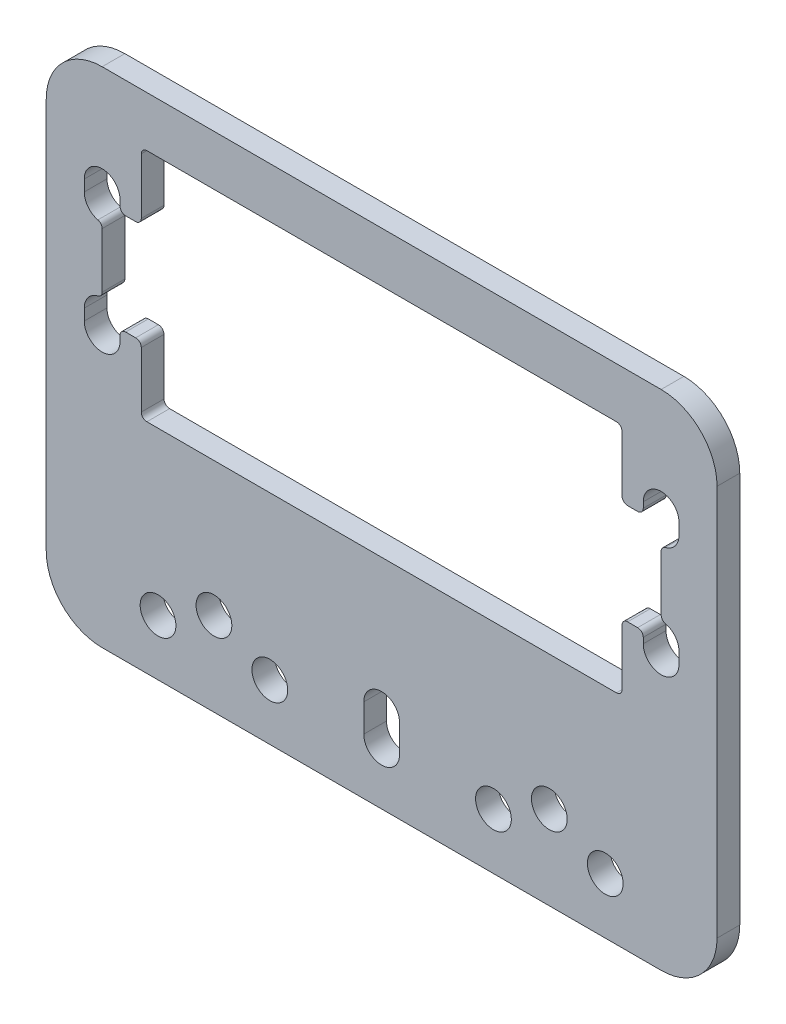
from build123d import *

# Parameters (mm, degrees)
SKETCH1_W           = 60
SKETCH1_H           = 45
BOSS_EXTRUDE1_DEPTH = 2.032
FILLET1_R           = 5
SKETCH2_W           = 41
SKETCH2_H           = 21
CUT_EXTRUDE1_DEPTH  = 3.032
FILLET2_R           = 0.5
CUT_EXTRUDE2_DEPTH  = 3.032
SKETCH4_R           = 1.6
CUT_EXTRUDE3_DEPTH  = 3.032
CUT_EXTRUDE4_DEPTH  = 3.032
FILLET3_R           = 0.5


with BuildPart() as part:
    # Sketch1 → Boss-Extrude1 (new body)
    with BuildSketch(Plane.XY):
        Rectangle(SKETCH1_W, SKETCH1_H)
    extrude(amount=BOSS_EXTRUDE1_DEPTH)

    # Fillet1
    fillet1_edges = [part.edges().sort_by_distance(p)[0] for p in [
        (30, -22.5, 1.016),
        (-30, -22.5, 1.016),
        (-30, 22.5, 1.016),
        (30, 22.5, 1.016),
    ]]
    fillet(fillet1_edges, radius=FILLET1_R)

    # Sketch2 → Cut-Extrude1 (cut, through all)
    with BuildSketch(Plane.XY.offset(2.032)):
        with Locations((0, 7.5)):
            Rectangle(SKETCH2_W, SKETCH2_H)
    extrude(amount=-CUT_EXTRUDE1_DEPTH, mode=Mode.SUBTRACT)

    # Fillet2
    fillet2_edges = [part.edges().sort_by_distance(p)[0] for p in [
        (20.5, 18, 1.016),
        (20.5, -3, 1.016),
        (-20.5, -3, 1.016),
        (-20.5, 18, 1.016),
    ]]
    fillet(fillet2_edges, radius=FILLET2_R)

    # Sketch3 → Cut-Extrude2 (cut, through all)
    with BuildSketch(Plane.XY.offset(2.032)):
        with BuildLine():
            Line((-23.4, 3), (-23.4, 2))
            ThreePointArc((-23.4, 2), (-25, 0.4), (-26.6, 2))
            Line((-26.6, 2), (-26.6, 3))
            ThreePointArc((-26.6, 3), (-25, 4.6), (-23.4, 3))
        make_face()
        with BuildLine():
            Line((-23.4, 12), (-23.4, 13))
            ThreePointArc((-23.4, 13), (-25, 14.6), (-26.6, 13))
            Line((-26.6, 13), (-26.6, 12))
            ThreePointArc((-26.6, 12), (-25, 10.4), (-23.4, 12))
        make_face()
        with BuildLine():
            Line((23.4, 3), (23.4, 2))
            ThreePointArc((23.4, 2), (25, 0.4), (26.6, 2))
            Line((26.6, 2), (26.6, 3))
            ThreePointArc((26.6, 3), (25, 4.6), (23.4, 3))
        make_face()
        with BuildLine():
            Line((23.4, 12), (23.4, 13))
            ThreePointArc((23.4, 13), (25, 14.6), (26.6, 13))
            Line((26.6, 13), (26.6, 12))
            ThreePointArc((26.6, 12), (25, 10.4), (23.4, 12))
        make_face()
    extrude(amount=-CUT_EXTRUDE2_DEPTH, mode=Mode.SUBTRACT)

    # Sketch4 → Cut-Extrude3 (cut, through all)
    with BuildSketch(Plane.XY.offset(2.032)):
        with Locations((-15, -15)):
            Circle(SKETCH4_R)
        with Locations((15, -15)):
            Circle(SKETCH4_R)
        with Locations((10, -17.5)):
            Circle(SKETCH4_R)
        with Locations((-10, -17.5)):
            Circle(SKETCH4_R)
        with Locations((20, -17.5)):
            Circle(SKETCH4_R)
        with Locations((-20, -17.5)):
            Circle(SKETCH4_R)
        with BuildLine():
            Line((1.6, -15), (1.6, -17.5))
            ThreePointArc((1.6, -17.5), (0, -19.1), (-1.6, -17.5))
            Line((-1.6, -17.5), (-1.6, -15))
            ThreePointArc((-1.6, -15), (0, -13.4), (1.6, -15))
        make_face()
    extrude(amount=-CUT_EXTRUDE3_DEPTH, mode=Mode.SUBTRACT)

    # Sketch5 → Cut-Extrude4 (cut, through all)
    with BuildSketch(Plane.XY.offset(2.032)):
        with BuildLine():
            Line((-21, -3), (21, -3))
            ThreePointArc((21, -3), (21.353553391, -2.853553391), (21.5, -2.5))
            Line((21.5, -2.5), (21.5, 3))
            Line((21.5, 3), (23.4, 3))
            ThreePointArc((23.4, 3), (24.53137085, 3.46862915), (25, 4.6))
            Line((25, 4.6), (25, 10.4))
            ThreePointArc((25, 10.4), (24.53137085, 11.53137085), (23.4, 12))
            Line((23.4, 12), (21.5, 12))
            Line((21.5, 12), (21.5, 17.5))
            ThreePointArc((21.5, 17.5), (21.353553391, 17.853553391), (21, 18))
            Line((21, 18), (-21, 18))
            ThreePointArc((-21, 18), (-21.353553391, 17.853553391), (-21.5, 17.5))
            Line((-21.5, 17.5), (-21.5, 12))
            Line((-21.5, 12), (-23.4, 12))
            ThreePointArc((-23.4, 12), (-24.53137085, 11.53137085), (-25, 10.4))
            Line((-25, 10.4), (-25, 4.6))
            ThreePointArc((-25, 4.6), (-24.53137085, 3.46862915), (-23.4, 3))
            Line((-23.4, 3), (-21.5, 3))
            Line((-21.5, 3), (-21.5, -2.5))
            ThreePointArc((-21.5, -2.5), (-21.353553391, -2.853553391), (-21, -3))
        make_face()
    extrude(amount=-CUT_EXTRUDE4_DEPTH, mode=Mode.SUBTRACT)

    # Fillet3
    fillet3_edges = [part.edges().sort_by_distance(p)[0] for p in [
        (23.4, 3, 1.016),
        (23.4, 12, 1.016),
        (-21.5, 3, 1.016),
        (-25, 4.6, 1.016),
        (-25, 10.4, 1.016),
        (-21.5, 12, 1.016),
        (21.5, 12, 1.016),
        (25, 10.4, 1.016),
        (25, 4.6, 1.016),
        (21.5, 3, 1.016),
        (-23.4, 3, 1.016),
        (-23.4, 12, 1.016),
    ]]
    fillet(fillet3_edges, radius=FILLET3_R)


solid = part.part
